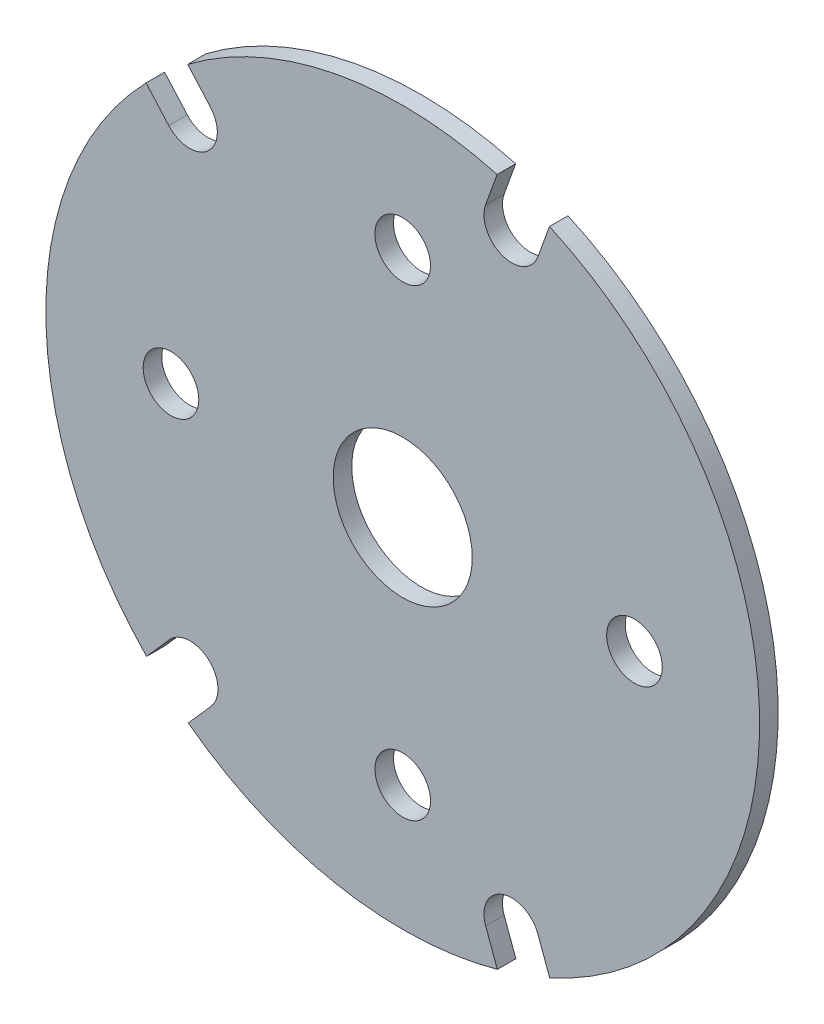
from build123d import *

# Parameters (mm, degrees)
MODEL_R             = 7.5
MODEL_R_2           = 3
BOSS_EXTRUDE1_DEPTH = 2


with BuildPart() as part:
    # Model → Boss-Extrude1 (new body)
    with BuildSketch(Plane.XY):
        with BuildLine():
            Line((8.939806713, 33.678513972), (10.182427979, 37.129074328))
            ThreePointArc((10.182427979, 37.129074328), (-7.25127288, 37.810964569), (-23.195832576, 30.727892071))
            Line((-23.195832576, 30.727892071), (-20.753740651, 27.969309055))
            ThreePointArc((-20.753740651, 27.969309055), (-21.011453059, 23.734502764), (-25.246259349, 23.992215172))
            Line((-25.246259349, 23.992215172), (-27.688351274, 26.750798188))
            ThreePointArc((-27.688351274, 26.750798188), (-38.49998136, -0.037885337), (-27.635650248, -26.805238954))
            Line((-27.635650248, -26.805238954), (-25.18187917, -24.022447477))
            ThreePointArc((-25.18187917, -24.022447477), (-20.947588277, -23.756401179), (-20.68154198, -27.990692072))
            Line((-20.68154198, -27.990692072), (-23.135313057, -30.773483549))
            ThreePointArc((-23.135313057, -30.773483549), (-7.20176697, -37.82042507), (10.206567261, -37.122445835))
            Line((10.206567261, -37.122445835), (8.946777939, -33.697393363))
            ThreePointArc((8.946777939, -33.697393363), (10.726715594, -29.846255768), (14.577853189, -31.626193423))
            Line((14.577853189, -31.626193423), (15.850365451, -35.085836388))
            ThreePointArc((15.850365451, -35.085836388), (38.499997947, 0.01257318), (15.82744568, 35.096181605))
            Line((15.82744568, 35.096181605), (14.584824415, 31.645621248))
            ThreePointArc((14.584824415, 31.645621248), (10.745869202, 29.839558759), (8.939806713, 33.678513972))
        make_face()
        Circle(MODEL_R, mode=Mode.SUBTRACT)
        with Locations((0, 25)):
            Circle(MODEL_R_2, mode=Mode.SUBTRACT)
        with Locations((25, 0)):
            Circle(MODEL_R_2, mode=Mode.SUBTRACT)
        with Locations((0, -25)):
            Circle(MODEL_R_2, mode=Mode.SUBTRACT)
        with Locations((-25, 0)):
            Circle(MODEL_R_2, mode=Mode.SUBTRACT)
    extrude(amount=BOSS_EXTRUDE1_DEPTH)


solid = part.part
